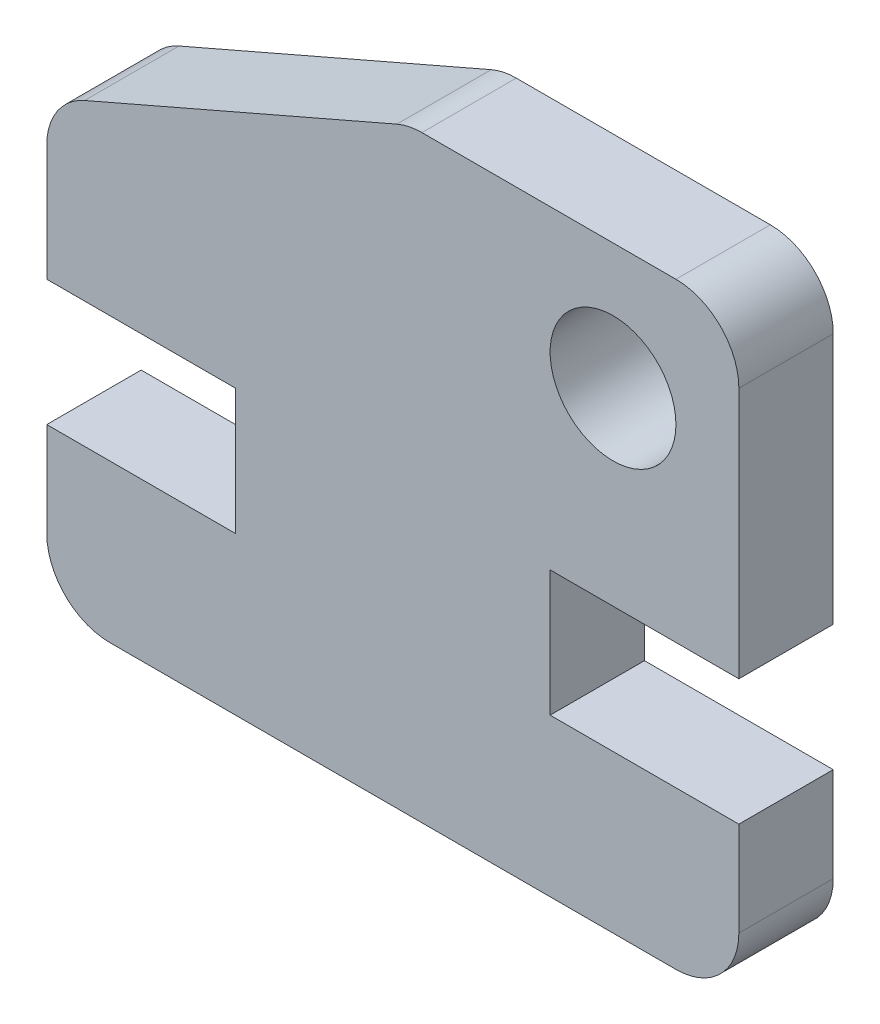
from build123d import *

# Parameters (mm, degrees)
AUFSATZ_LINEAR_AUSTRAGEN1_DEPTH = 3
F_4_0_4_DURCHMESSER_BOHRUNG1_D  = 4
SCHNITT_LINEAR_AUSTRAGEN1_DEPTH = 3
VERRUNDUNG2_R                   = 2


with BuildPart() as part:
    # Skizze1 → Aufsatz-Linear austragen1 (new body)
    with BuildSketch(Plane.XY):
        Polygon((-11, 5), (-11, 0), (11, 0), (11, 5), (5, 5), (5, 9), (11, 9), (11, 19), (-11, 19), (-11, 9), (-5, 9), (-5, 5), align=None)
    extrude(amount=AUFSATZ_LINEAR_AUSTRAGEN1_DEPTH)

    # Ø4.0 (4) Durchmesser Bohrung1 (through all)
    with Locations(Plane.XY.offset(3)):
        with Locations((7, 15)):
            Hole(F_4_0_4_DURCHMESSER_BOHRUNG1_D / 2)

    # Skizze4 → Schnitt-Linear austragen1 (cut)
    with BuildSketch(Plane.XY.offset(3)):
        Polygon((-11, 14), (0.509428342, 19), (-11, 19), align=None)
    extrude(amount=-SCHNITT_LINEAR_AUSTRAGEN1_DEPTH, mode=Mode.SUBTRACT)

    # Verrundung2
    verrundung2_edges = [part.edges().sort_by_distance(p)[0] for p in [
        (11, 19, 1.5),
        (11, 0, 1.5),
        (-11, 0, 1.5),
        (-11, 14, 1.5),
        (0.509428342, 19, 1.5),
    ]]
    fillet(verrundung2_edges, radius=VERRUNDUNG2_R)


solid = part.part
